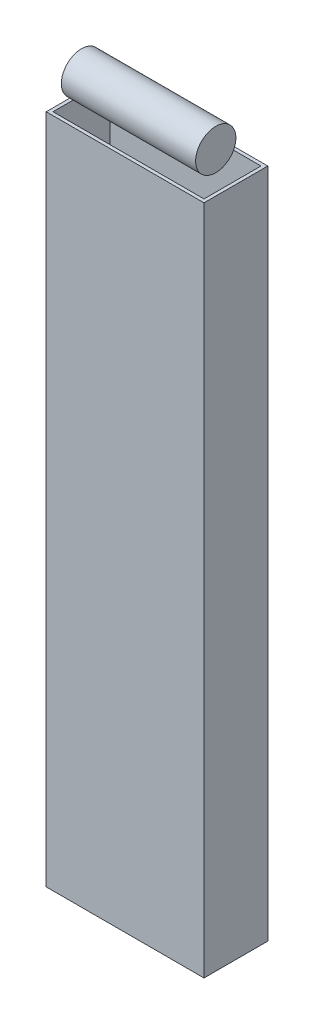
from build123d import *

# Parameters (mm, degrees)
SKETCH_1_W      = 47
SKETCH_1_H      = 19
SKETCH_1_W_2    = 45
SKETCH_1_H_2    = 17
EXTRUDE_1_DEPTH = 200
SKETCH_2_R      = 6
EXTRUDE_2_DEPTH = 40


with BuildPart() as part:
    # 草图1 → 凸台-拉伸1 (new body)
    with BuildSketch(Plane(origin=(0, 0, 0), x_dir=(1, 0, 0), z_dir=(0, 1, 0))):
        Rectangle(SKETCH_1_W, SKETCH_1_H)
        Rectangle(SKETCH_1_W_2, SKETCH_1_H_2, mode=Mode.SUBTRACT)
    extrude(amount=EXTRUDE_1_DEPTH)


with BuildPart() as body_2:
    # 草图2 → 凸台-拉伸2 (new body)
    with BuildSketch(Plane(origin=(-22.5, 0, 0), x_dir=(0, 0, -1), z_dir=(1, 0, 0))):
        with Locations((0, 206)):
            Circle(SKETCH_2_R)
    extrude(amount=EXTRUDE_2_DEPTH)


solid = Compound([part.part, body_2.part])
